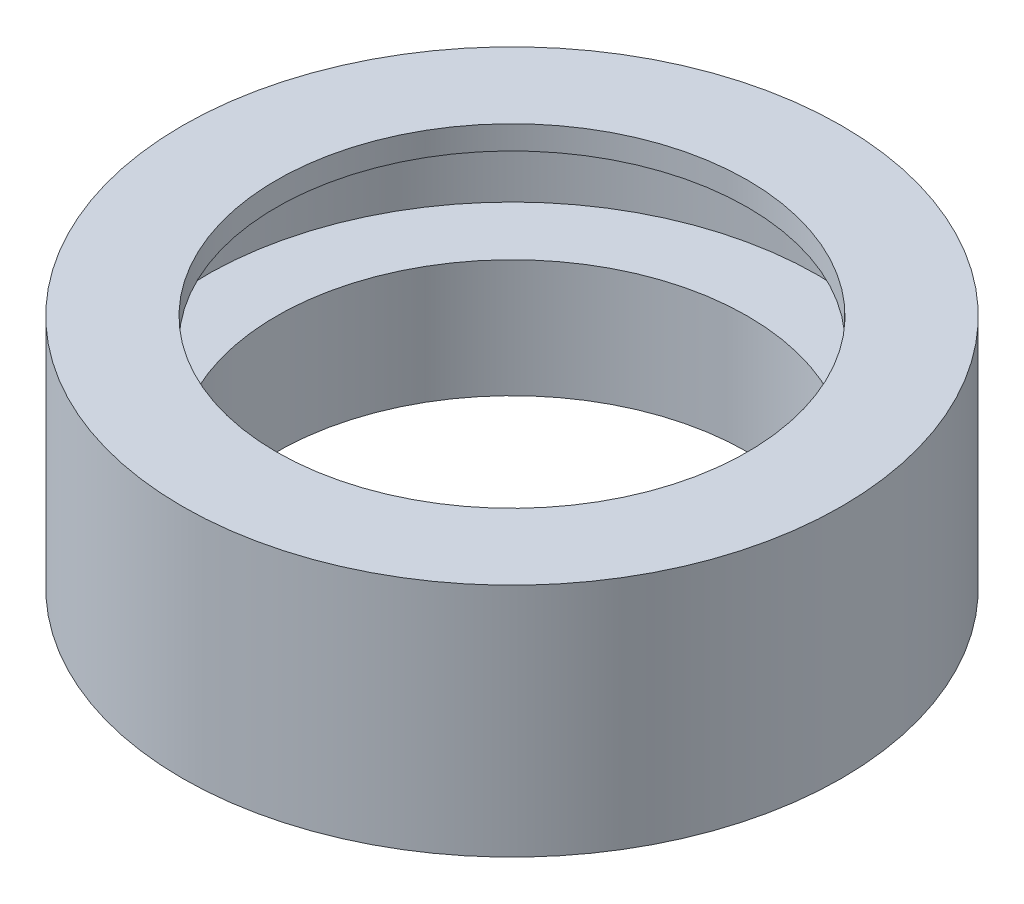
from build123d import *

# Parameters (mm, degrees)
SKETCH3_R          = 7
CUT_EXTRUDE1_DEPTH = 5


with BuildPart() as part:
    # Sketch2 → Revolve1 (revolve)
    with BuildSketch(Plane(origin=(0, 0, 0), x_dir=(0, 0, -1), z_dir=(1, 0, 0))):
        Polygon((5, 3.711600936), (7, 3.711600936), (7, 13.711600936), (5, 13.711600936), (5, 8.211600936), (6.5, 8.211600936), (6.5, 6.211600936), (5, 6.211600936), align=None)
    revolve(axis=Axis((0, 0, 0), (0, 1, 0)))

    # Sketch3 → Cut-Extrude1 (cut)
    with BuildSketch(Plane(origin=(0, 13.711600936, 0), x_dir=(1, 0, 0), z_dir=(0, 1, 0))):
        Circle(SKETCH3_R)
    extrude(amount=-CUT_EXTRUDE1_DEPTH, mode=Mode.SUBTRACT)


solid = part.part
